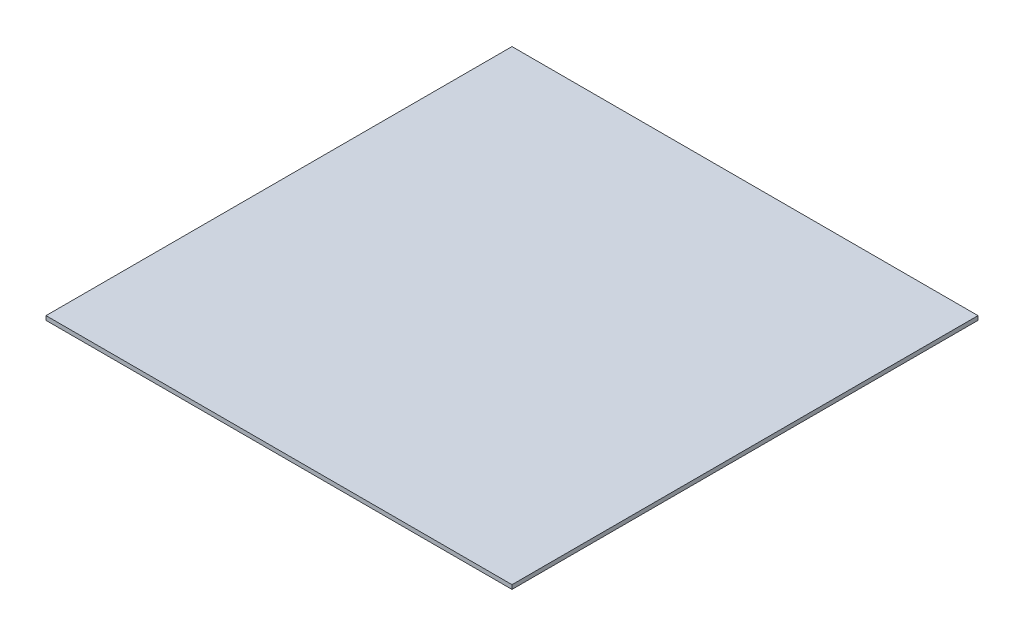
from build123d import *

# Parameters (mm, degrees)
SKETCH1_W           = 225
SKETCH1_H           = 225
BOSS_EXTRUDE1_DEPTH = 2


with BuildPart() as part:
    # Sketch1 → Boss-Extrude1 (new body)
    with BuildSketch(Plane(origin=(0, 0, 0), x_dir=(1, 0, 0), z_dir=(0, 1, 0))):
        Rectangle(SKETCH1_W, SKETCH1_H)
    extrude(amount=BOSS_EXTRUDE1_DEPTH)


solid = part.part
